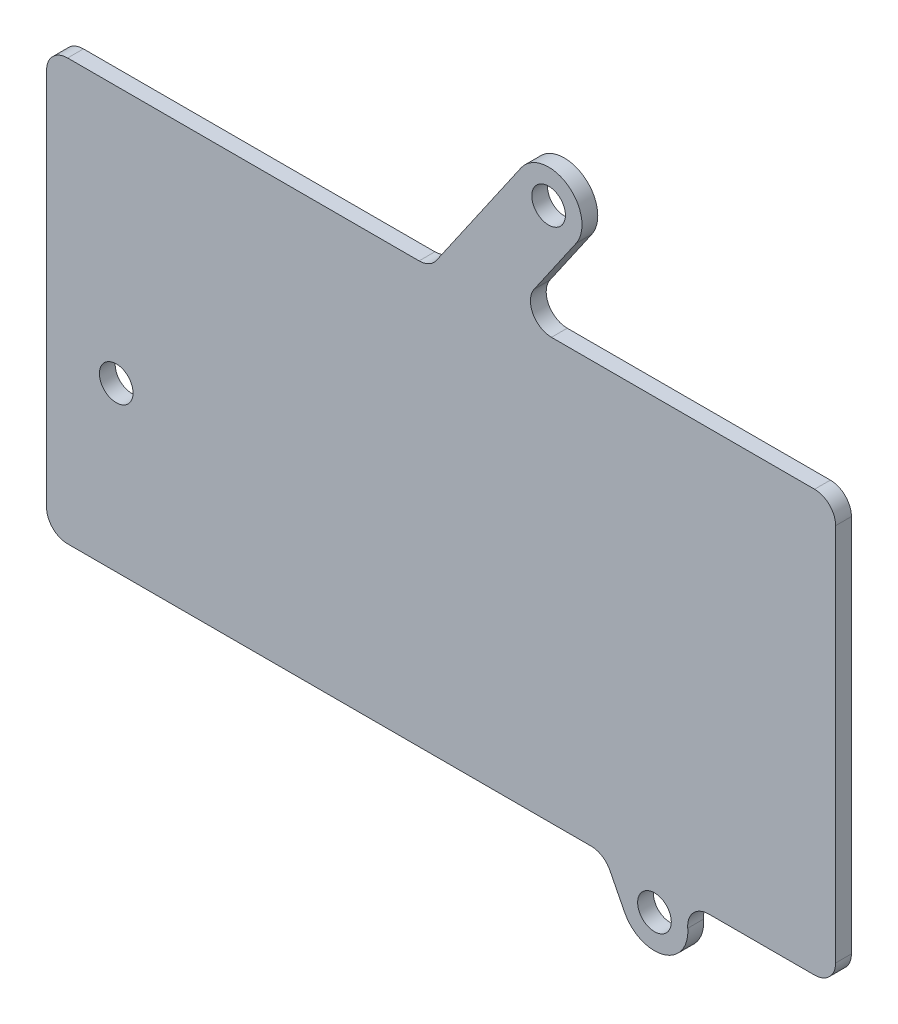
from build123d import *

# Parameters (mm, degrees)
SKETCH1_W           = 69.1
SKETCH1_H           = 34.1
BOSS_EXTRUDE1_DEPTH = 1.5
BOSS_EXTRUDE2_DEPTH = 1.5
SKETCH3_R           = 1.6
BOSS_EXTRUDE3_DEPTH = 1.5
SKETCH3_2_R         = 1.6
CUT_EXTRUDE1_DEPTH  = 85.057646739


with BuildPart() as part:
    # Sketch1 → Boss-Extrude1 (new body)
    with BuildSketch(Plane.XY.offset(19)):
        with BuildLine():
            Line((4.325559412, 33.249665151), (-65.674440588, 33.249665151))
            ThreePointArc((-65.674440588, 33.249665151), (-66.063349318, 33.088573881), (-66.224440588, 32.699665151))
            Line((-66.224440588, 32.699665151), (-66.224440588, -2.300334849))
            ThreePointArc((-66.224440588, -2.300334849), (-66.063349318, -2.689243578), (-65.674440588, -2.850334849))
            Line((-65.674440588, -2.850334849), (4.325559412, -2.850334849))
            ThreePointArc((4.325559412, -2.850334849), (4.714468141, -2.689243578), (4.875559412, -2.300334849))
            Line((4.875559412, -2.300334849), (4.875559412, 32.699665151))
            ThreePointArc((4.875559412, 32.699665151), (4.714468141, 33.088573881), (4.325559412, 33.249665151))
        make_face()
        with Locations((-30.674440588, 15.199665151)):
            Rectangle(SKETCH1_W, SKETCH1_H, mode=Mode.SUBTRACT)
    extrude(amount=-BOSS_EXTRUDE1_DEPTH)

    # Sketch2 → Boss-Extrude2 (add)
    with BuildSketch(Plane.XY.offset(19)):
        with BuildLine():
            Line((6.825559412, -2.800334849), (6.825559412, 33.199665151))
            ThreePointArc((6.825559412, 33.199665151), (6.239772974, 34.613878714), (4.825559412, 35.199665151))
            Line((4.825559412, 35.199665151), (-66.174440588, 35.199665151))
            ThreePointArc((-66.174440588, 35.199665151), (-67.588654151, 34.613878714), (-68.174440588, 33.199665151))
            Line((-68.174440588, 33.199665151), (-68.174440588, -2.800334849))
            ThreePointArc((-68.174440588, -2.800334849), (-67.588654151, -4.214548411), (-66.174440588, -4.800334849))
            Line((-66.174440588, -4.800334849), (4.825559412, -4.800334849))
            ThreePointArc((4.825559412, -4.800334849), (6.239772974, -4.214548411), (6.825559412, -2.800334849))
        make_face()
    extrude(amount=BOSS_EXTRUDE2_DEPTH)

    # Sketch3 → Boss-Extrude3 (add)
    with BuildSketch(Plane.XY.offset(20.5)):
        with Locations((-61.556671003, 10.73089265)):
            Circle(SKETCH3_R)
        with BuildLine():
            Line((-14.637085978, -5.893524128), (-13.224518296, -8.670350201))
            ThreePointArc((-13.224518296, -8.670350201), (-9.526572542, -10.284819436), (-7.230629421, -6.966693625))
            ThreePointArc((-7.230629421, -6.966693625), (-7.001208277, -5.857177596), (-6.205806077, -5.050334849))
            ThreePointArc((-6.205806077, -5.050334849), (-5.737560241, -4.863843176), (-5.237560241, -4.800334849))
            Line((-5.237560241, -4.800334849), (-16.419694829, -4.800334849))
            ThreePointArc((-16.419694829, -4.800334849), (-15.919694829, -4.863843176), (-15.451448992, -5.050334849))
            ThreePointArc((-15.451448992, -5.050334849), (-14.981104401, -5.410925772), (-14.637085978, -5.893524128))
        make_face()
        with Locations((-10.394626745, -7.230788182)):
            Circle(SKETCH3_R, mode=Mode.SUBTRACT)
        with BuildLine():
            Line((-23.070638788, 47.711150724), (-31.122037847, 36.06249216))
            ThreePointArc((-31.122037847, 36.06249216), (-31.425094294, 35.716922893), (-31.799038979, 35.449665151))
            ThreePointArc((-31.799038979, 35.449665151), (-32.267284816, 35.263173478), (-32.767284816, 35.199665151))
            Line((-32.767284816, 35.199665151), (-20.185587119, 35.199665151))
            ThreePointArc((-20.185587119, 35.199665151), (-20.685587119, 35.263173478), (-21.153832956, 35.449665151))
            ThreePointArc((-21.153832956, 35.449665151), (-22.132771787, 36.743077954), (-21.830834088, 38.336838142))
            Line((-21.830834088, 38.336838142), (-17.846979662, 44.100626478))
            ThreePointArc((-17.846979662, 44.100626478), (-18.653547102, 48.517718164), (-23.070638788, 47.711150724))
        make_face()
        with Locations((-20.458809225, 45.905888601)):
            Circle(SKETCH3_R, mode=Mode.SUBTRACT)
    extrude(amount=-BOSS_EXTRUDE3_DEPTH)

    # Sketch3_2 → Cut-Extrude1 (cut, through all)
    with BuildSketch(Plane.XY.offset(20.5)):
        with Locations((-61.556671003, 10.73089265)):
            Circle(SKETCH3_2_R)
    extrude(amount=-CUT_EXTRUDE1_DEPTH, mode=Mode.SUBTRACT)


solid = part.part
